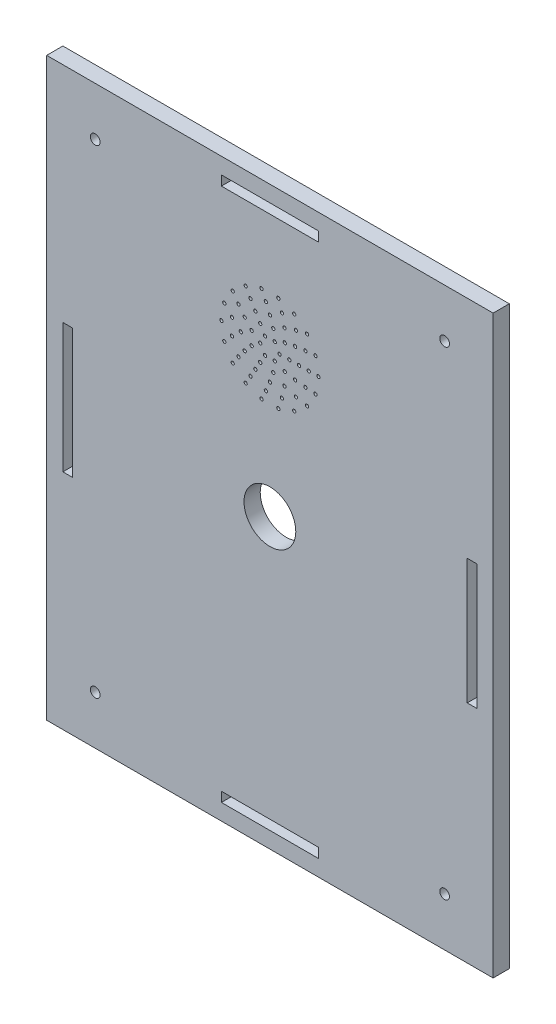
from build123d import *

# Parameters (mm, degrees)
SKETCH2_W           = 138
SKETCH2_H           = 178
BOSS_EXTRUDE1_DEPTH = 5
SKETCH3_W           = 30
SKETCH3_H           = 3
CUT_EXTRUDE1_DEPTH  = 6
SKETCH4_W           = 30
SKETCH4_H           = 3
CUT_EXTRUDE2_DEPTH  = 8
SKETCH6_W           = 3
SKETCH6_H           = 38.70967742
CUT_EXTRUDE3_DEPTH  = 8
SKETCH5_W           = 3
SKETCH5_H           = 40
CUT_EXTRUDE4_DEPTH  = 8
SKETCH8_R           = 1.5
CUT_EXTRUDE5_DEPTH  = 6
SKETCH10_R          = 8
CUT_EXTRUDE8_DEPTH  = 10
SKETCH11_R          = 0.5
CUT_EXTRUDE10_DEPTH = 10


with BuildPart() as part:
    # Sketch2 → Boss-Extrude1 (new body)
    with BuildSketch(Plane.XY):
        Rectangle(SKETCH2_W, SKETCH2_H)
    extrude(amount=BOSS_EXTRUDE1_DEPTH)

    # Sketch3 → Cut-Extrude1 (cut, through all)
    with BuildSketch(Plane.XY.offset(5)):
        with Locations((0, 82.5)):
            Rectangle(SKETCH3_W, SKETCH3_H)
    extrude(amount=-CUT_EXTRUDE1_DEPTH, mode=Mode.SUBTRACT)

    # Sketch4 → Cut-Extrude2 (cut)
    with BuildSketch(Plane.XY.offset(5)):
        with Locations((0, -82.5)):
            Rectangle(SKETCH4_W, SKETCH4_H)
    extrude(amount=-CUT_EXTRUDE2_DEPTH, mode=Mode.SUBTRACT)

    # Sketch6 → Cut-Extrude3 (cut)
    with BuildSketch(Plane.XY.offset(5)):
        with Locations((62.5, 0)):
            Rectangle(SKETCH6_W, SKETCH6_H)
    extrude(amount=-CUT_EXTRUDE3_DEPTH, mode=Mode.SUBTRACT)

    # Sketch5 → Cut-Extrude4 (cut)
    with BuildSketch(Plane.XY.offset(5)):
        with Locations((-62.5, 0)):
            Rectangle(SKETCH5_W, SKETCH5_H)
    extrude(amount=-CUT_EXTRUDE4_DEPTH, mode=Mode.SUBTRACT)

    # Sketch8 → Cut-Extrude5 (cut, through all)
    with BuildSketch(Plane.XY.offset(5)):
        with Locations((54, -74)):
            Circle(SKETCH8_R)
        with Locations((54, 74)):
            Circle(SKETCH8_R)
        with Locations((-54, 74)):
            Circle(SKETCH8_R)
        with Locations((-54, -74)):
            Circle(SKETCH8_R)
    extrude(amount=-CUT_EXTRUDE5_DEPTH, mode=Mode.SUBTRACT)

    # Sketch10 → Cut-Extrude8 (cut)
    with BuildSketch(Plane(origin=(0, 0, 0), x_dir=(-1, 0, 0), z_dir=(0, 0, -1))):
        Circle(SKETCH10_R)
    extrude(amount=-CUT_EXTRUDE8_DEPTH, mode=Mode.SUBTRACT)

    # Sketch11 → Cut-Extrude10 (cut)
    with BuildSketch(Plane(origin=(0, 0, 0), x_dir=(-1, 0, 0), z_dir=(0, 0, -1))):
        with Locations((-3, 45)):
            Circle(SKETCH11_R)
        with Locations((-1.5, 47.598076211)):
            Circle(SKETCH11_R)
        with Locations((1.5, 47.598076211)):
            Circle(SKETCH11_R)
        with Locations((3, 45)):
            Circle(SKETCH11_R)
        with Locations((1.5, 42.401923789)):
            Circle(SKETCH11_R)
        with Locations((-1.5, 42.401923789)):
            Circle(SKETCH11_R)
        with Locations((-6, 45)):
            Circle(SKETCH11_R)
        with Locations((-9, 45)):
            Circle(SKETCH11_R)
        with Locations((-12, 45)):
            Circle(SKETCH11_R)
        with Locations((-15, 45)):
            Circle(SKETCH11_R)
        with Locations((-4.596266659, 48.856725658)):
            Circle(SKETCH11_R)
        with Locations((-1.041889066, 50.908846518)):
            Circle(SKETCH11_R)
        with Locations((3, 50.196152423)):
            Circle(SKETCH11_R)
        with Locations((5.638155725, 47.05212086)):
            Circle(SKETCH11_R)
        with Locations((5.638155725, 42.94787914)):
            Circle(SKETCH11_R)
        with Locations((3, 39.803847577)):
            Circle(SKETCH11_R)
        with Locations((-1.041889066, 39.091153482)):
            Circle(SKETCH11_R)
        with Locations((-4.596266659, 41.143274342)):
            Circle(SKETCH11_R)
        with Locations((-7.794228634, 49.5)):
            Circle(SKETCH11_R)
        with Locations((-4.5, 52.794228634)):
            Circle(SKETCH11_R)
        with Locations((0, 54)):
            Circle(SKETCH11_R)
        with Locations((4.5, 52.794228634)):
            Circle(SKETCH11_R)
        with Locations((7.794228634, 49.5)):
            Circle(SKETCH11_R)
        with Locations((9, 45)):
            Circle(SKETCH11_R)
        with Locations((7.794228634, 40.5)):
            Circle(SKETCH11_R)
        with Locations((4.5, 37.205771366)):
            Circle(SKETCH11_R)
        with Locations((0, 36)):
            Circle(SKETCH11_R)
        with Locations((-4.5, 37.205771366)):
            Circle(SKETCH11_R)
        with Locations((-10.962545492, 49.880839717)):
            Circle(SKETCH11_R)
        with Locations((-8.029567276, 53.917737906)):
            Circle(SKETCH11_R)
        with Locations((-3.708203932, 56.412678196)):
            Circle(SKETCH11_R)
        with Locations((1.254341559, 56.934262744)):
            Circle(SKETCH11_R)
        with Locations((6, 55.392304845)):
            Circle(SKETCH11_R)
        with Locations((9.708203932, 52.053423028)):
            Circle(SKETCH11_R)
        with Locations((11.737771209, 47.49494029)):
            Circle(SKETCH11_R)
        with Locations((11.737771209, 42.50505971)):
            Circle(SKETCH11_R)
        with Locations((9.708203932, 37.946576972)):
            Circle(SKETCH11_R)
        with Locations((6, 34.607695155)):
            Circle(SKETCH11_R)
        with Locations((1.254341559, 33.065737256)):
            Circle(SKETCH11_R)
        with Locations((-3.708203932, 33.587321804)):
            Circle(SKETCH11_R)
        with Locations((-14.095389312, 50.13030215)):
            Circle(SKETCH11_R)
        with Locations((-11.490666647, 54.641814145)):
            Circle(SKETCH11_R)
        with Locations((-7.5, 57.990381057)):
            Circle(SKETCH11_R)
        with Locations((-2.604722665, 59.772116295)):
            Circle(SKETCH11_R)
        with Locations((2.604722665, 59.772116295)):
            Circle(SKETCH11_R)
        with Locations((7.5, 57.990381057)):
            Circle(SKETCH11_R)
        with Locations((11.490666647, 54.641814145)):
            Circle(SKETCH11_R)
        with Locations((14.095389312, 50.13030215)):
            Circle(SKETCH11_R)
        with Locations((15, 45)):
            Circle(SKETCH11_R)
        with Locations((14.095389312, 39.86969785)):
            Circle(SKETCH11_R)
        with Locations((11.490666647, 35.358185855)):
            Circle(SKETCH11_R)
        with Locations((7.5, 32.009618943)):
            Circle(SKETCH11_R)
        with Locations((-7.794228634, 40.5)):
            Circle(SKETCH11_R)
        with Locations((-8.029567276, 36.082262094)):
            Circle(SKETCH11_R)
        with Locations((-10.962545492, 40.119160283)):
            Circle(SKETCH11_R)
        with Locations((2.604722665, 30.227883705)):
            Circle(SKETCH11_R)
        with Locations((-2.604722665, 30.227883705)):
            Circle(SKETCH11_R)
        with Locations((-7.5, 32.009618943)):
            Circle(SKETCH11_R)
        with Locations((-11.490666647, 35.358185855)):
            Circle(SKETCH11_R)
        with Locations((-14.095389312, 39.86969785)):
            Circle(SKETCH11_R)
    extrude(amount=-CUT_EXTRUDE10_DEPTH, mode=Mode.SUBTRACT)


solid = part.part
